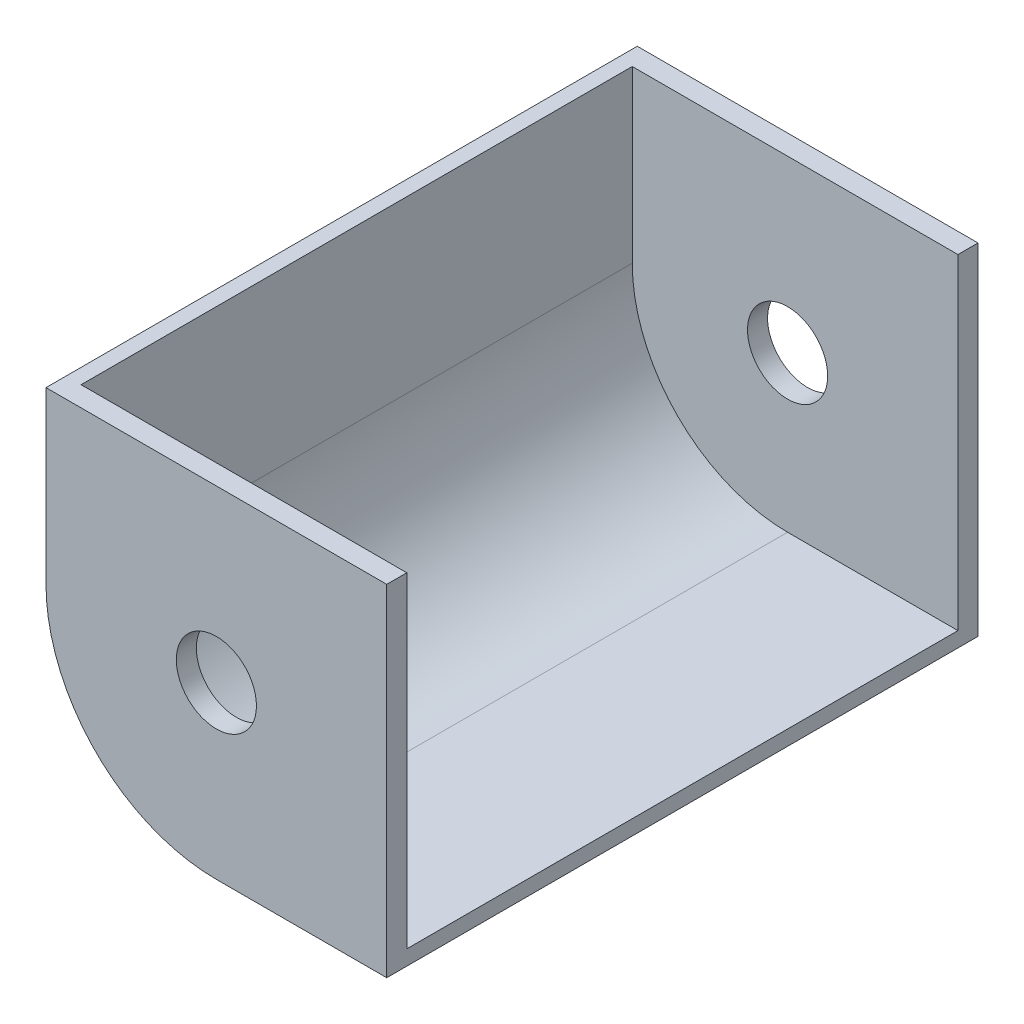
from build123d import *

# Parameters (mm, degrees)
BOSS_EXTRUDE1_DEPTH = 2
BOSS_EXTRUDE2_DEPTH = 55
BOSS_EXTRUDE3_DEPTH = 2
SKETCH4_R           = 4
CUT_EXTRUDE1_DEPTH  = 60


with BuildPart() as part:
    # Sketch1 → Boss-Extrude1 (new body)
    with BuildSketch(Plane.XY):
        with BuildLine():
            Line((-17, 0), (0, 0))
            Line((0, 0), (0, 17))
            Line((0, 17), (0, 34))
            Line((0, 34), (-17, 34))
            Line((-17, 34), (-34, 34))
            Line((-34, 34), (-34, 17))
            ThreePointArc((-34, 17), (-29.02081528, 4.97918472), (-17, 0))
        make_face()
    extrude(amount=BOSS_EXTRUDE1_DEPTH)

    # Sketch2 → Boss-Extrude2 (add)
    with BuildSketch(Plane.XY.offset(2)):
        with BuildLine():
            Line((-17, 0), (0, 0))
            Line((0, 0), (0, 1.5))
            Line((0, 1.5), (-17, 1.5))
            ThreePointArc((-17, 1.5), (-27.960155108, 6.039844892), (-32.5, 17))
            Line((-32.5, 17), (-32.5, 34))
            Line((-32.5, 34), (-34, 34))
            Line((-34, 34), (-34, 17))
            ThreePointArc((-34, 17), (-29.02081528, 4.97918472), (-17, 0))
        make_face()
    extrude(amount=BOSS_EXTRUDE2_DEPTH)

    # Sketch3 → Boss-Extrude3 (add)
    with BuildSketch(Plane.XY.offset(57)):
        with BuildLine():
            Line((0, 0), (0, 1.5))
            Line((0, 1.5), (0, 34))
            Line((0, 34), (-32.5, 34))
            Line((-32.5, 34), (-34, 34))
            Line((-34, 34), (-34, 17))
            ThreePointArc((-34, 17), (-29.02081528, 4.97918472), (-17, 0))
            Line((-17, 0), (0, 0))
        make_face()
    extrude(amount=BOSS_EXTRUDE3_DEPTH)

    # Sketch4 → Cut-Extrude1 (cut, through all)
    with BuildSketch(Plane.XY.offset(59)):
        with Locations((-17, 17)):
            Circle(SKETCH4_R)
    extrude(amount=-CUT_EXTRUDE1_DEPTH, mode=Mode.SUBTRACT)


solid = part.part
